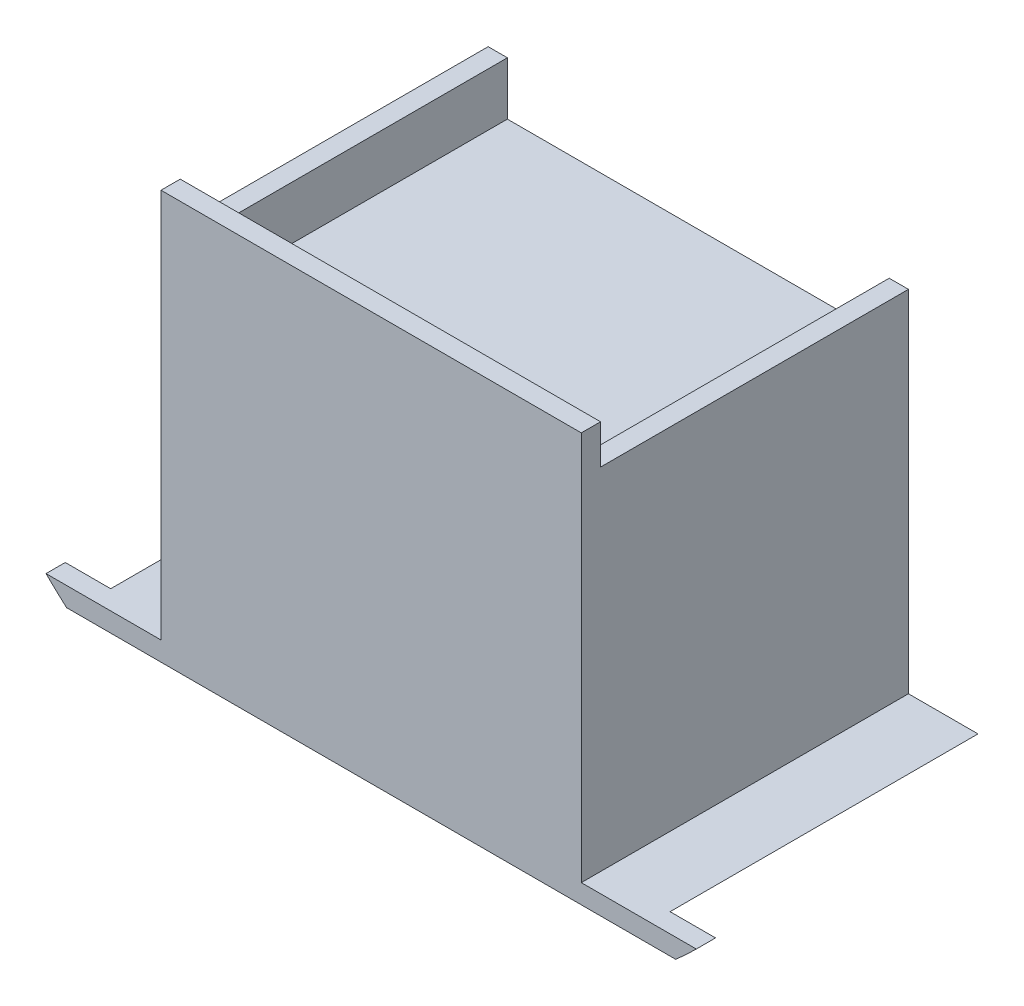
from build123d import *

# Parameters (mm, degrees)
BOSS_EXTRUDE2_DEPTH = 50.8
SKETCH3_W           = 69.342
SKETCH3_H           = 67.437
BOSS_EXTRUDE3_DEPTH = 3.175
BOSS_EXTRUDE4_DEPTH = 53.975
BOSS_EXTRUDE6_DEPTH = 3.175
SKETCH6_W           = 62.992
SKETCH6_H           = 49.022
BOSS_EXTRUDE7_DEPTH = 25.4


with BuildPart() as part:
    # Sketch2 → Boss-Extrude2 (new body)
    with BuildSketch(Plane.XY):
        Polygon((-34.671, -49.022), (-31.496, -49.022), (-31.496, 0), (31.496, 0), (31.496, -49.022), (34.671, -49.022), (34.671, 11.938), (31.496, 11.938), (31.496, 3.175), (-31.496, 3.175), (-31.496, 11.938), (-34.671, 11.938), align=None)
    extrude(amount=BOSS_EXTRUDE2_DEPTH)

    # Sketch3 → Boss-Extrude3 (add)
    with BuildSketch(Plane.XY.offset(50.8)):
        with Locations((0, -15.3035)):
            Rectangle(SKETCH3_W, SKETCH3_H)
    extrude(amount=BOSS_EXTRUDE3_DEPTH)

    # Sketch4 → Boss-Extrude4 (add)
    with BuildSketch(Plane.XY.offset(53.975)):
        with BuildLine():
            Line((-34.671, -49.022), (-42.1386, -49.022))
            ThreePointArc((-42.1386, -49.022), (-44.170473584, -47.470511893), (-46.145273507, -45.847))
            Line((-46.145273507, -45.847), (-34.671, -45.847))
            Line((-34.671, -45.847), (-34.671, -49.022))
        make_face()
        with BuildLine():
            Line((34.671, -45.847), (34.671, -49.022))
            Line((34.671, -49.022), (42.1386, -49.022))
            ThreePointArc((42.1386, -49.022), (44.170473584, -47.470511893), (46.145273507, -45.847))
            Line((46.145273507, -45.847), (34.671, -45.847))
        make_face()
    extrude(amount=-BOSS_EXTRUDE4_DEPTH)

    # Sketch5 → Boss-Extrude6 (add)
    with BuildSketch(Plane(origin=(0, 0, 53.975), x_dir=(-1, 0, 0), z_dir=(0, 0, -1))):
        with BuildLine():
            Line((42.1386, -49.022), (50.239896596, -49.022))
            ThreePointArc((50.239896596, -49.022), (51.966635807, -47.460510217), (53.64486804, -45.847))
            Line((53.64486804, -45.847), (46.145273507, -45.847))
            ThreePointArc((46.145273507, -45.847), (44.170473584, -47.470511893), (42.1386, -49.022))
        make_face()
        with BuildLine():
            Line((-46.145273507, -45.847), (-53.64486804, -45.847))
            ThreePointArc((-53.64486804, -45.847), (-51.966635807, -47.460510217), (-50.239896596, -49.022))
            Line((-50.239896596, -49.022), (-42.1386, -49.022))
            ThreePointArc((-42.1386, -49.022), (-44.170473584, -47.470511893), (-46.145273507, -45.847))
        make_face()
    extrude(amount=BOSS_EXTRUDE6_DEPTH)

    # Sketch6 → Boss-Extrude7 (add)
    with BuildSketch(Plane(origin=(0, 0, 50.8), x_dir=(-1, 0, 0), z_dir=(0, 0, -1))):
        with Locations((0, -24.511)):
            Rectangle(SKETCH6_W, SKETCH6_H)
    extrude(amount=BOSS_EXTRUDE7_DEPTH)


solid = part.part
